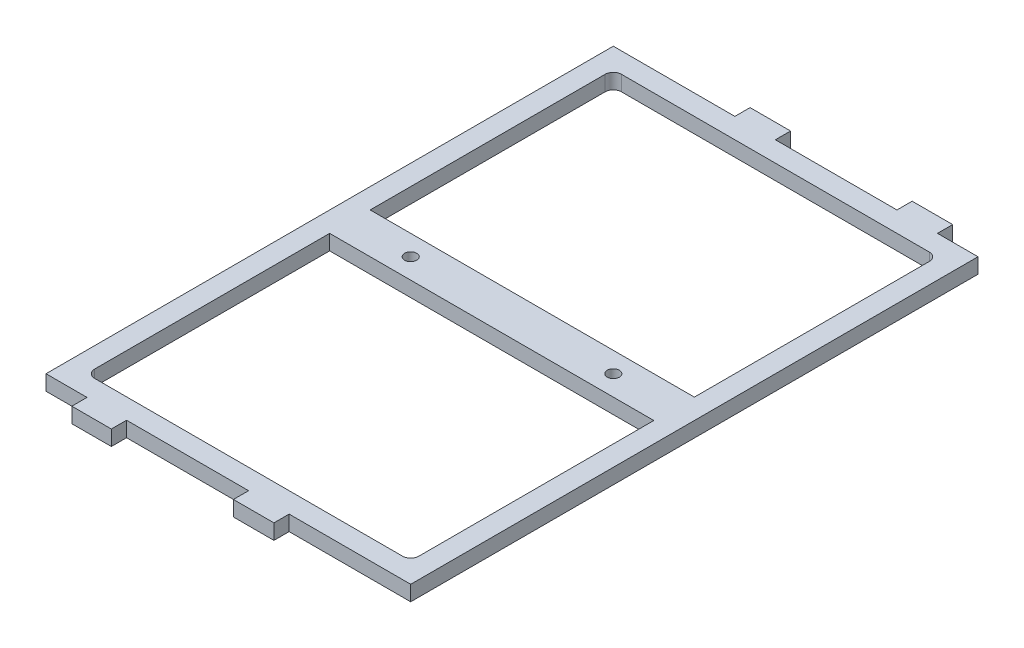
from build123d import *

# Parameters (mm, degrees)
SKETCH1_W                 = 114.3
SKETCH1_H                 = 177.8
SKETCH1_W_2               = 101.6
SKETCH1_H_2               = 165.1
BOSS_EXTRUDE1_DEPTH       = 4.7625
SKETCH2_W                 = 12.38677804
SKETCH2_H                 = 4.7625
SKETCH2_W_2               = 12.7
BOSS_EXTRUDE2_DEPTH       = 4.7625
SKETCH3_W                 = 12.7
SKETCH3_H                 = 4.7625
BOSS_EXTRUDE3_DEPTH       = 4.7625
FILLET1_R                 = 2.54
SKETCH4_W                 = 114.3
SKETCH4_H                 = 12.7
BOSS_EXTRUDE4_DEPTH       = 4.7625
F_6_CLEARANCE_HOLE1_D     = 3.7973
F_6_CLEARANCE_HOLE1_DEPTH = 25.4
F_6_CLEARANCE_HOLE1_TIP   = 1.140824014


with BuildPart() as part:
    # Sketch1 → Boss-Extrude1 (new body)
    with BuildSketch(Plane(origin=(0, 0, 0), x_dir=(1, 0, 0), z_dir=(0, 1, 0))):
        Rectangle(SKETCH1_W, SKETCH1_H)
        Rectangle(SKETCH1_W_2, SKETCH1_H_2, mode=Mode.SUBTRACT)
    extrude(amount=BOSS_EXTRUDE1_DEPTH)

    # Sketch2 → Boss-Extrude2 (add)
    with BuildSketch(Plane.XY.offset(88.9)):
        with Locations((-38.1, 2.38125)):
            Rectangle(SKETCH2_W, SKETCH2_H)
        with Locations((12.7, 2.38125)):
            Rectangle(SKETCH2_W_2, SKETCH2_H)
    extrude(amount=BOSS_EXTRUDE2_DEPTH)

    # Sketch3 → Boss-Extrude3 (add)
    with BuildSketch(Plane(origin=(0, 0, -88.9), x_dir=(-1, 0, 0), z_dir=(0, 0, -1))):
        with Locations((-38.1, 2.38125)):
            Rectangle(SKETCH3_W, SKETCH3_H)
        with Locations((12.7, 2.38125)):
            Rectangle(SKETCH3_W, SKETCH3_H)
    extrude(amount=BOSS_EXTRUDE3_DEPTH)

    # Fillet1
    fillet1_edges = [part.edges().sort_by_distance(p)[0] for p in [
        (50.8, 2.38125, 82.55),
        (50.8, 2.38125, -82.55),
        (-50.8, 2.38125, -82.55),
        (-50.8, 2.38125, 82.55),
    ]]
    fillet(fillet1_edges, radius=FILLET1_R)

    # Sketch4 → Boss-Extrude4 (add)
    with BuildSketch(Plane(origin=(0, 4.7625, 0), x_dir=(1, 0, 0), z_dir=(0, 1, 0))):
        Rectangle(SKETCH4_W, SKETCH4_H)
    extrude(amount=-BOSS_EXTRUDE4_DEPTH)

    # #6 Clearance Hole1
    with Locations(Plane(origin=(0, 4.7625, 0), x_dir=(-1, 0, 0), z_dir=(0, 1, 0))):
        with Locations((31.75, 0), (-31.75, 0)):
            Hole(F_6_CLEARANCE_HOLE1_D / 2, depth=F_6_CLEARANCE_HOLE1_DEPTH)
            with Locations((0, 0, -(F_6_CLEARANCE_HOLE1_DEPTH + F_6_CLEARANCE_HOLE1_TIP / 2))):  # 118° drill point
                Cone(0, F_6_CLEARANCE_HOLE1_D / 2, F_6_CLEARANCE_HOLE1_TIP, mode=Mode.SUBTRACT)


solid = part.part
